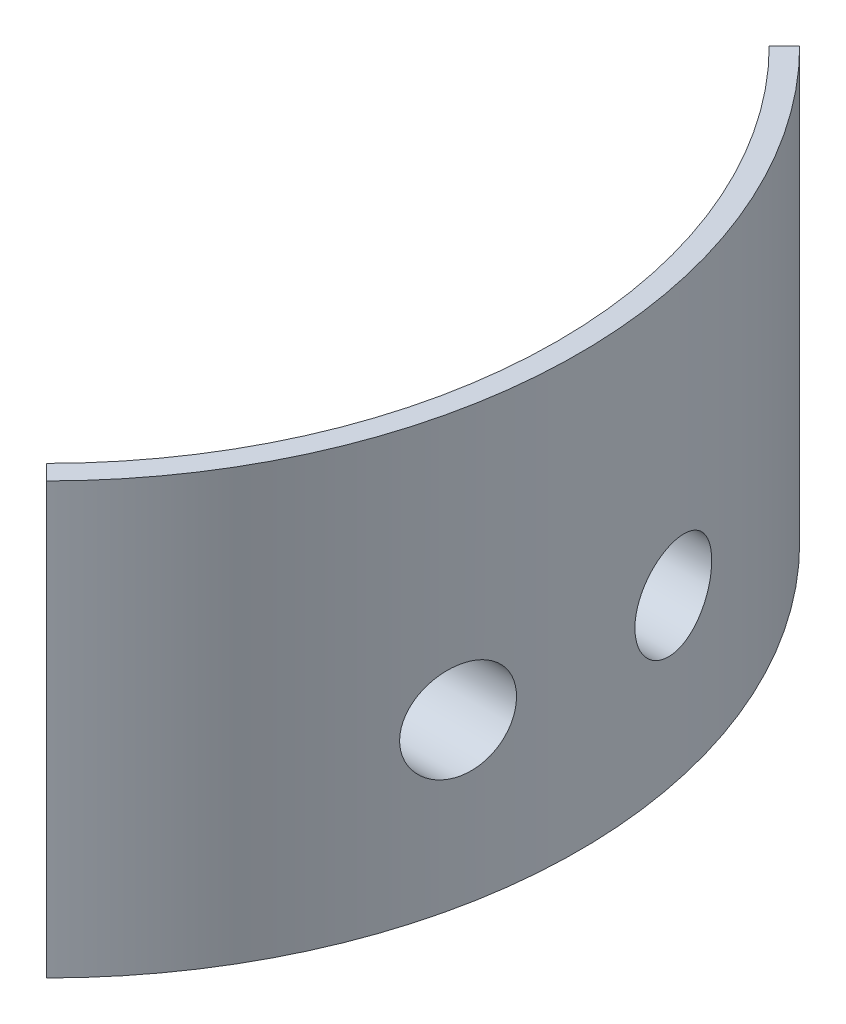
from build123d import *

# Parameters (mm, degrees)
SKETCH1_W      = 2
SKETCH1_H      = 40
MAIN_ANGLE     = 90
SUPPORT_DEPTH  = 10
SKETCH6_W      = 1
SKETCH6_H      = 2.9
FIX_2_DEPTH    = 10
SKETCH9_R      = 1.6
HOLES_DEPTH    = 5
SKETCH10_R     = 4.5
BIGHOLES_DEPTH = 17.5


with BuildPart() as part:
    # Sketch1 → Main (revolve, symmetric)
    with BuildSketch(Plane.XY) as main_sk:
        with Locations((48.5, 20)):
            Rectangle(SKETCH1_W, SKETCH1_H)
    revolve(axis=Axis((0, -0.284703924, 0), (0, 1, 0)), revolution_arc=MAIN_ANGLE / 2)
    revolve(main_sk.sketch, axis=Axis((0, -0.284703924, 0), (0, -1, 0)), revolution_arc=MAIN_ANGLE / 2)

    # Sketch2 → Support (add)
    with BuildSketch(Plane(origin=(0, 10, 0), x_dir=(-1, 0, 0), z_dir=(0, -1, 0))):
        with BuildLine():
            Line((-47.236109069, -5), (-33, -5))
            Line((-33, -5), (-33, 5))
            Line((-33, 5), (-47.236109069, 5))
            ThreePointArc((-47.236109069, 5), (-46.422799712, 10.058512159), (-45.069390943, 15))
            Line((-45.069390943, 15), (-30, 15))
            Line((-30, 15), (-30, -15))
            Line((-30, -15), (-45.069390943, -15))
            ThreePointArc((-45.069390943, -15), (-46.422799712, -10.058512159), (-47.236109069, -5))
        make_face()
    extrude(amount=-SUPPORT_DEPTH)

    # Sketch6 → Fix 2 (add)
    with BuildSketch(Plane(origin=(0, 10, 0), x_dir=(1, 0, 0), z_dir=(0, 1, 0))):
        with Locations((29.5, -10)):
            Rectangle(SKETCH6_W, SKETCH6_H)
        with Locations((29.5, 10)):
            Rectangle(SKETCH6_W, SKETCH6_H)
    extrude(amount=FIX_2_DEPTH)

    # Sketch9 → Holes (cut, through all)
    with BuildSketch(Plane(origin=(33, 0, 0), x_dir=(0, 0, -1), z_dir=(1, 0, 0))):
        with Locations((10, 15)):
            Circle(SKETCH9_R)
        with Locations((-10, 15)):
            Circle(SKETCH9_R)
    extrude(amount=-HOLES_DEPTH, mode=Mode.SUBTRACT)

    # Sketch10 → BigHoles (cut, through all)
    with BuildSketch(Plane(origin=(33, 0, 0), x_dir=(0, 0, -1), z_dir=(1, 0, 0))):
        with Locations((10, 15)):
            Circle(SKETCH10_R)
        with Locations((-10, 15)):
            Circle(SKETCH10_R)
    extrude(amount=BIGHOLES_DEPTH, mode=Mode.SUBTRACT)


solid = part.part
